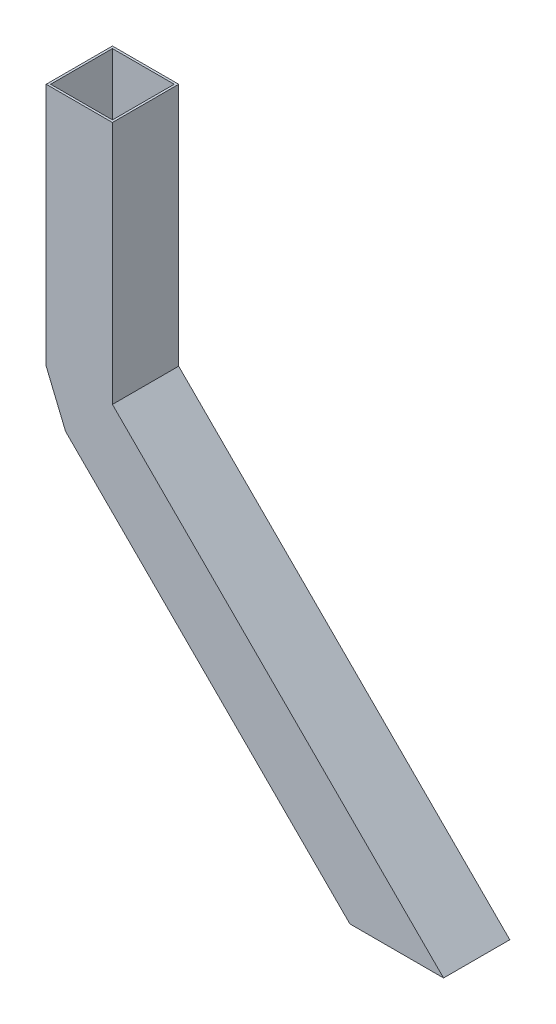
from build123d import *

# Parameters (mm, degrees)
CROQUIS1_W              = 60
CROQUIS1_H              = 60
CROQUIS1_W_2            = 56
CROQUIS1_H_2            = 56
SALIENTE_EXTRUIR1_DEPTH = 221.22
CROQUIS3_W              = 60
CROQUIS3_H              = 60
CROQUIS3_W_2            = 56
CROQUIS3_H_2            = 56
SALIENTE_EXTRUIR2_DEPTH = 424.26
CORTAR_EXTRUIR1_DEPTH   = 61
CROQUIS14_W             = 60
CROQUIS14_H             = 60
CROQUIS14_W_2           = 56
CROQUIS14_H_2           = 56


with BuildPart() as part:
    # Croquis1 → Saliente-Extruir1 (new body)
    with BuildSketch(Plane(origin=(0, 0, 0), x_dir=(1, 0, 0), z_dir=(0, 1, 0))):
        Rectangle(CROQUIS1_W, CROQUIS1_H)
        Rectangle(CROQUIS1_W_2, CROQUIS1_H_2, mode=Mode.SUBTRACT)
    extrude(amount=SALIENTE_EXTRUIR1_DEPTH)



with BuildPart() as body_2:
    # Croquis3 → Saliente-Extruir2 (new body)
    with BuildSketch(Plane(origin=(15, -15, 0), x_dir=(0, 0, -1), z_dir=(0.707106781, -0.707106781, 0))):
        with Locations((0, -8.786796564)):
            Rectangle(CROQUIS3_W, CROQUIS3_H)
        with Locations((0, -8.786796564)):
            Rectangle(CROQUIS3_W_2, CROQUIS3_H_2, mode=Mode.SUBTRACT)
    extrude(amount=SALIENTE_EXTRUIR2_DEPTH)

    # Croquis10 → Cortar-Extruir1 (cut, through all)
    with BuildSketch(Plane.XY.offset(30)):
        Polygon((287.570716115, -342.423529857), (329.997122986, -299.997122986), (245.144309244, -299.997122986), align=None)
    extrude(amount=-CORTAR_EXTRUIR1_DEPTH, mode=Mode.SUBTRACT)


with BuildPart() as part_1:
    add(part.part)

    add(body_2.part)  # Barrer2 merges body 2
    # Barrer2: sweep along a path in Croquis13
    with BuildLine(Plane.XY.offset(30)) as barrer2_path:
        Line((-12.426406871, -42.426406871), (-30, 0))
    # Croquis14 → Barrer2 (sweep)
    with BuildSketch(Plane(origin=(15, -15, 0), x_dir=(0, 0, 1), z_dir=(-0.707106781, 0.707106781, 0))):
        with Locations((0, -8.786796564)):
            Rectangle(CROQUIS14_W, CROQUIS14_H)
        with Locations((0, -8.786796564)):
            Rectangle(CROQUIS14_W_2, CROQUIS14_H_2, mode=Mode.SUBTRACT)
    sweep(path=barrer2_path.line)


solid = part_1.part
